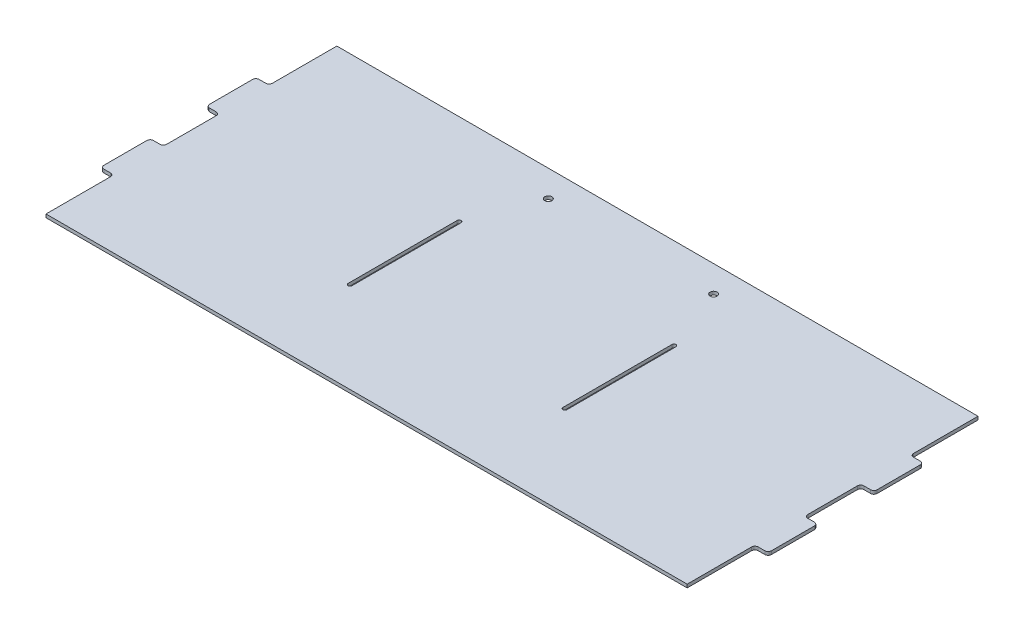
from build123d import *

# Parameters (mm, degrees)
SKETCH1_W                        = 615.95
SKETCH1_H                        = 279.4
BOSS_EXTRUDE1_DEPTH              = 3.175
SKETCH2_W                        = 641.35
SKETCH2_H                        = 47.625
BOSS_EXTRUDE2_DEPTH              = 3.175
FILLET1_R                        = 3.175
CUT_EXTRUDE1_DEPTH               = 4.175
F_17_64_0_26563_DIAMETER_HOLE1_D = 6.747002


with BuildPart() as part:
    # Sketch1 → Boss-Extrude1 (new body)
    with BuildSketch(Plane(origin=(0, 0, 0), x_dir=(1, 0, 0), z_dir=(0, 1, 0))):
        with Locations((307.975, -139.7)):
            Rectangle(SKETCH1_W, SKETCH1_H)
    extrude(amount=BOSS_EXTRUDE1_DEPTH)

    # Sketch2 → Boss-Extrude2 (add, through all)
    with BuildSketch(Plane(origin=(0, 3.175, 0), x_dir=(1, 0, 0), z_dir=(0, 1, 0))):
        with Locations((307.975, -88.9)):
            Rectangle(SKETCH2_W, SKETCH2_H)
        with Locations((307.975, -190.5)):
            Rectangle(SKETCH2_W, SKETCH2_H)
    extrude(amount=-BOSS_EXTRUDE2_DEPTH)

    # Fillet1
    fillet1_edges = [part.edges().sort_by_distance(p)[0] for p in [
        (628.65, 1.5875, 112.7125),
        (-12.7, 1.5875, 65.0875),
        (628.65, 1.5875, 65.0875),
        (0, 1.5875, 112.7125),
        (615.95, 1.5875, 112.7125),
        (-12.7, 1.5875, 112.7125),
        (0, 1.5875, 65.0875),
        (615.95, 1.5875, 65.0875),
        (628.65, 1.5875, 214.3125),
        (-12.7, 1.5875, 166.6875),
        (628.65, 1.5875, 166.6875),
        (0, 1.5875, 214.3125),
        (615.95, 1.5875, 214.3125),
        (-12.7, 1.5875, 214.3125),
        (0, 1.5875, 166.6875),
        (615.95, 1.5875, 166.6875),
    ]]
    fillet(fillet1_edges, radius=FILLET1_R)

    # Sketch3 → Cut-Extrude1 (cut, through all)
    with BuildSketch(Plane(origin=(0, 3.175, 0), x_dir=(1, 0, 0), z_dir=(0, 1, 0))):
        with BuildLine():
            Line((202.8825, -192.0875), (202.8825, -87.3125))
            ThreePointArc((202.8825, -87.3125), (204.7875, -85.4075), (206.6925, -87.3125))
            Line((206.6925, -87.3125), (206.6925, -192.0875))
            ThreePointArc((206.6925, -192.0875), (204.7875, -193.9925), (202.8825, -192.0875))
        make_face()
        with BuildLine():
            Line((409.2575, -192.0875), (409.2575, -87.3125))
            ThreePointArc((409.2575, -87.3125), (411.1625, -85.4075), (413.0675, -87.3125))
            Line((413.0675, -87.3125), (413.0675, -192.0875))
            ThreePointArc((413.0675, -192.0875), (411.1625, -193.9925), (409.2575, -192.0875))
        make_face()
    extrude(amount=-CUT_EXTRUDE1_DEPTH, mode=Mode.SUBTRACT)

    # 17/64 (0.26563) Diameter Hole1 (through all)
    with Locations(Plane(origin=(0, 3.175, 0), x_dir=(1, 0, 0), z_dir=(0, 1, 0))):
        with Locations((387.35, -25.4), (228.6, -25.4)):
            Hole(F_17_64_0_26563_DIAMETER_HOLE1_D / 2)


solid = part.part
